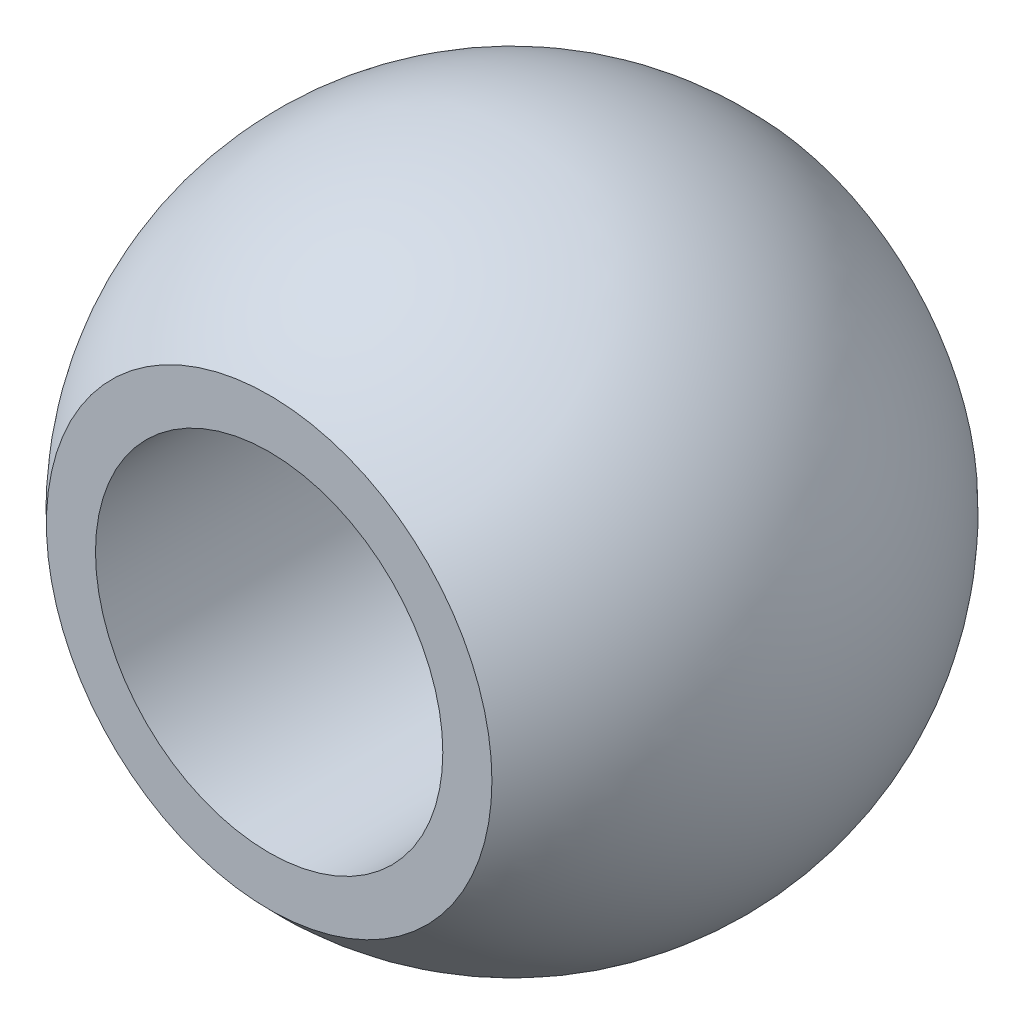
from build123d import *


with BuildPart() as part:
    # Sketch1 → Revolve1 (revolve)
    with BuildSketch(Plane(origin=(0, 0, 0), x_dir=(0, 0, -1), z_dir=(1, 0, 0))):
        with BuildLine():
            Line((-5.5499, 5.090783555), (-5.5499, 3.96875))
            Line((-5.5499, 3.96875), (5.5499, 3.96875))
            Line((5.5499, 3.96875), (5.5499, 5.090783555))
            ThreePointArc((5.5499, 5.090783555), (0, 7.5311), (-5.5499, 5.090783555))
        make_face()
    revolve(axis=Axis((0, 0, 31.258955331), (0, 0, -1)))


solid = part.part
